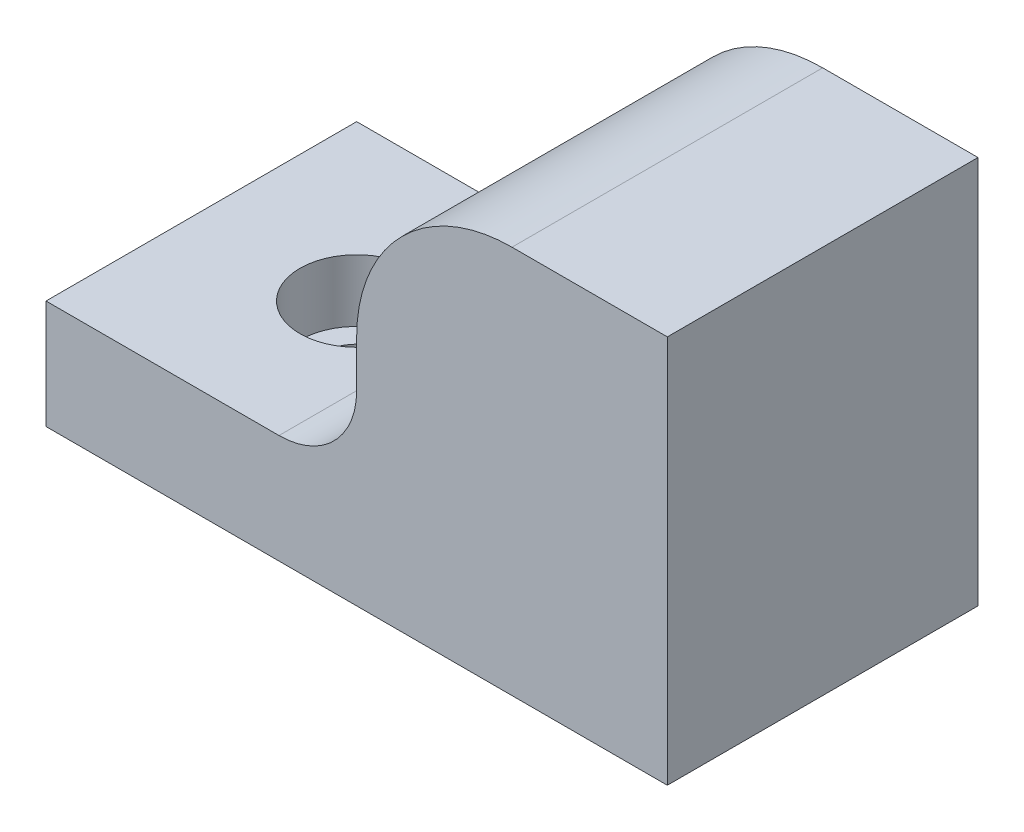
from build123d import *

# Parameters (mm, degrees)
EXTRUDE_1_DEPTH     = 10
SKETCH_2_R          = 3.65
CUT_EXTRUDE_1_DEPTH = 4
CUT_EXTRUDE_2_REACH = 5
SKETCH_3_R          = 2.25
SKETCH_4_R          = 3.4
FILLET_1_R          = 5
FILLET_2_R          = 10


with BuildPart() as part:
    # 草圖1 → 填料-伸長1 (new body, symmetric)
    with BuildSketch(Plane.XY):
        Polygon((20, 0), (20, 25), (0, 25), (0, 7), (-20, 7), (-20, 0), align=None)
    extrude(amount=EXTRUDE_1_DEPTH, both=True)

    # 草圖2 → 除料-伸長1 (cut)
    with BuildSketch(Plane(origin=(0, 7, 0), x_dir=(1, 0, 0), z_dir=(0, 1, 0))):
        with Locations((-10, 0)):
            Circle(SKETCH_2_R)
    extrude(amount=-CUT_EXTRUDE_1_DEPTH, mode=Mode.SUBTRACT)

    # 草圖3 → 除料-伸長2 (cut, up to next)
    with BuildSketch(Plane(origin=(0, 3, 0), x_dir=(1, 0, 0), z_dir=(0, 1, 0)), mode=Mode.PRIVATE) as cut_extrude_2_sk1:
        with Locations((-10, 0)):
            Circle(SKETCH_3_R)
    cut_extrude_2_tool1 = extrude(cut_extrude_2_sk1.sketch, amount=-CUT_EXTRUDE_2_REACH, mode=Mode.PRIVATE) & part.part
    add(cut_extrude_2_tool1.solids().sort_by_distance((-10, 3, 0))[0], mode=Mode.SUBTRACT)

    # 除料-掃出1: sweep along a path in 草圖5
    with BuildLine(Plane(origin=(10, 0, 10), x_dir=(0, 0, -1), z_dir=(1, 0, 0))) as sweep_1_path:
        Line((10, 0), (10, 12))
        ThreePointArc((10, 12), (12.343145751, 17.656854249), (18, 20))
        Line((18, 20), (20, 20))
    # 草圖4 → 除料-掃出1 (sweep, cut)
    with BuildSketch(Plane.XZ):
        with Locations((10, 0)):
            Circle(SKETCH_4_R)
    sweep(path=sweep_1_path.line, mode=Mode.SUBTRACT)

    # 圓角1
    fillet_1_edges = [part.edges().sort_by_distance(p)[0] for p in [
        (0, 7, 0),
    ]]
    fillet(fillet_1_edges, radius=FILLET_1_R)

    # 圓角2
    fillet_2_edges = [part.edges().sort_by_distance(p)[0] for p in [
        (0, 25, 0),
    ]]
    fillet(fillet_2_edges, radius=FILLET_2_R)


solid = part.part
